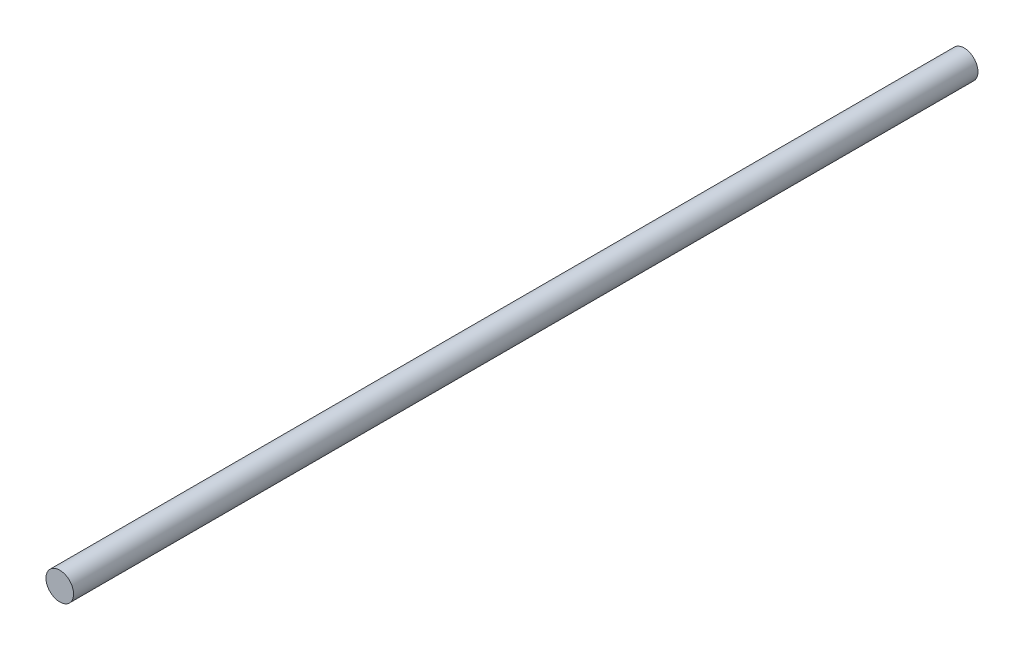
from build123d import *

# Parameters (mm, degrees)
SKETCH_1_R      = 5
EXTRUDE_1_DEPTH = 328


with BuildPart() as part:
    # Эскиз1 → Бобышка-Вытянуть1 (new body)
    with BuildSketch(Plane.XY):
        Circle(SKETCH_1_R)
    extrude(amount=EXTRUDE_1_DEPTH)


solid = part.part
